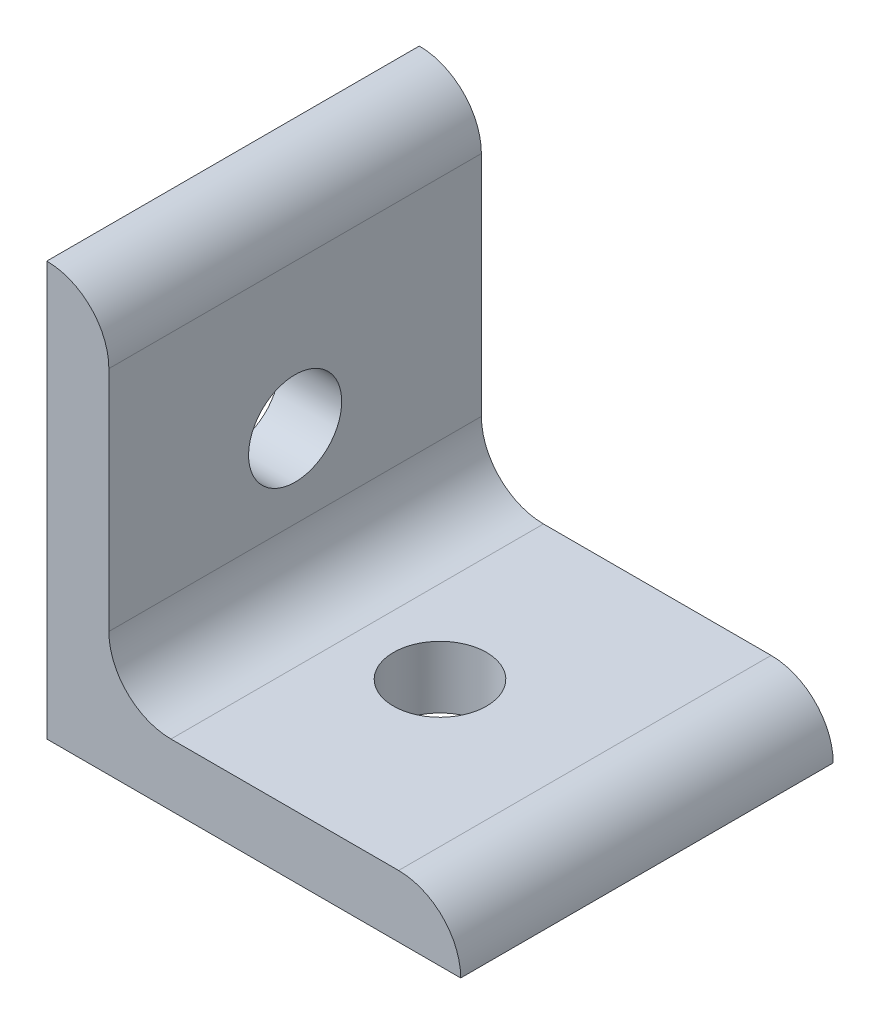
from build123d import *

# Parameters (mm, degrees)
BOSS_EXTRUDE1_DEPTH = 18
SKETCH2_R           = 4.5
CUT_EXTRUDE1_DEPTH  = 41
SKETCH3_R           = 4.5
CUT_EXTRUDE2_DEPTH  = 41


with BuildPart() as part:
    # Sketch1 → Boss-Extrude1 (new body, symmetric)
    with BuildSketch(Plane.XY):
        with BuildLine():
            Line((0, 0), (0, 40))
            ThreePointArc((0, 40), (4.242640687, 38.242640687), (6, 34))
            Line((6, 34), (6, 12))
            ThreePointArc((6, 12), (7.757359313, 7.757359313), (12, 6))
            Line((12, 6), (34, 6))
            ThreePointArc((34, 6), (38.242640687, 4.242640687), (40, 0))
            Line((40, 0), (0, 0))
        make_face()
    extrude(amount=BOSS_EXTRUDE1_DEPTH, both=True)

    # Sketch2 → Cut-Extrude1 (cut, through all)
    with BuildSketch(Plane(origin=(0, 0, 0), x_dir=(1, 0, 0), z_dir=(0, 1, 0))):
        with Locations((20, 0)):
            Circle(SKETCH2_R)
    extrude(amount=CUT_EXTRUDE1_DEPTH, mode=Mode.SUBTRACT)

    # Sketch3 → Cut-Extrude2 (cut, through all)
    with BuildSketch(Plane(origin=(0, 0, 0), x_dir=(0, 0, -1), z_dir=(1, 0, 0))):
        with Locations((0, 20)):
            Circle(SKETCH3_R)
    extrude(amount=CUT_EXTRUDE2_DEPTH, mode=Mode.SUBTRACT)


solid = part.part
